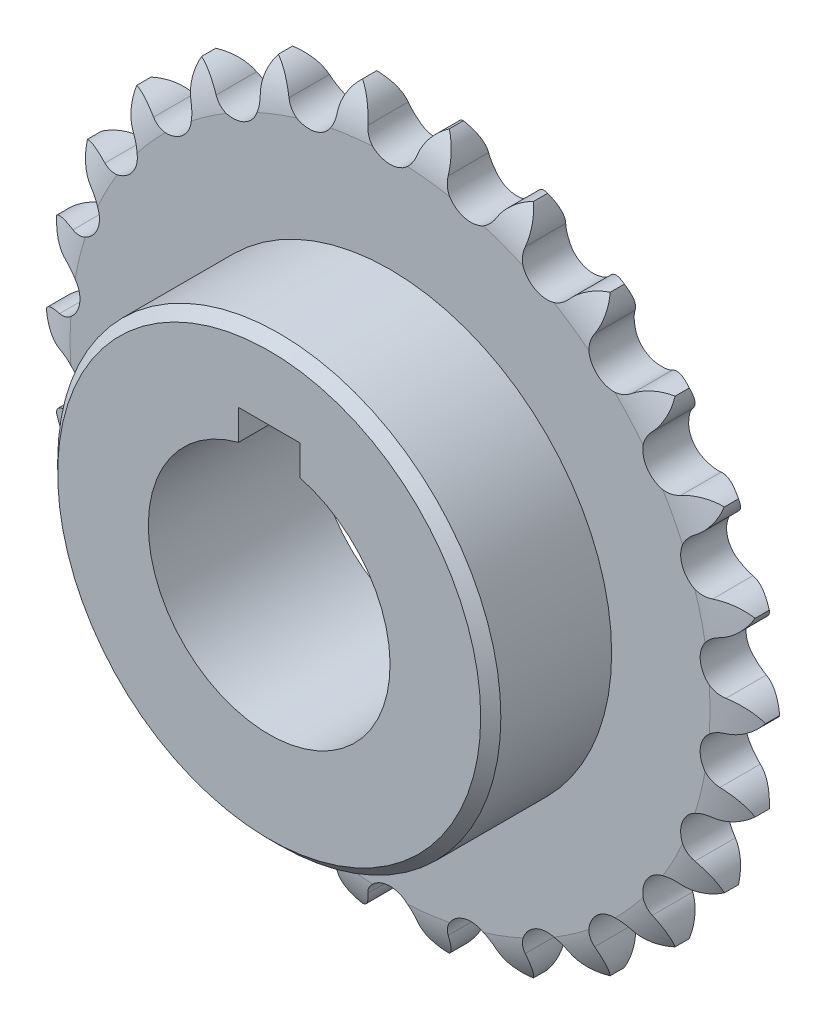
from build123d import *

# Parameters (mm, degrees)
SKETCH1_R           = 19.05
BOSS_EXTRUDE1_DEPTH = 3.6155
SKETCH2_W           = 19.05
SKETCH2_H           = 15.875
SKETCH3_W           = 9.65
SKETCH3_H           = 4.76
CUT_EXTRUDE1_DEPTH  = 27.281
CHAMFER2_SIZE       = 1.5875
SCALE_1_SCALE       = 0.5
SCALE_2_SCALE       = 2
SCALE_3_SCALE       = 0.111111111


with BuildPart() as part:
    # Sketch1 → Boss-Extrude1 (new body, symmetric)
    with BuildSketch(Plane.XY):
        with BuildLine():
            ThreePointArc((6.832203091, 56.268254805), (4.963717297, 54.655608899), (3.929721647, 52.414466562))
            ThreePointArc((3.929721647, 52.414466562), (0, 49.2633), (-3.929721647, 52.414466562))
            ThreePointArc((-3.929721647, 52.414466562), (-4.963717297, 54.655608899), (-6.832203091, 56.268254805))
            ThreePointArc((-6.832203091, 56.268254805), (-8.260462658, 54.25531154), (-8.728071806, 51.831841369))
            ThreePointArc((-8.728071806, 51.831841369), (-11.789479364, 47.831798034), (-16.359133961, 49.950953477))
            ThreePointArc((-16.359133961, 49.950953477), (-17.899424044, 51.879520935), (-20.099546463, 52.998148363))
            ThreePointArc((-20.099546463, 52.998148363), (-21.004574548, 50.701892683), (-20.87862145, 48.236937958))
            ThreePointArc((-20.87862145, 48.236937958), (-22.893797041, 43.620485829), (-27.837812873, 44.58447254))
            ThreePointArc((-27.837812873, 44.58447254), (-29.794881328, 46.088383789), (-32.198777254, 46.647982178))
            ThreePointArc((-32.198777254, 46.647982178), (-32.527976914, 44.201864118), (-31.815781507, 41.838679046))
            ThreePointArc((-31.815781507, 41.838679046), (-32.66761045, 36.87410954), (-37.698659287, 36.626904117))
            ThreePointArc((-37.698659287, 36.626904117), (-39.958768409, 37.618757301), (-42.426732148, 37.586804827))
            ThreePointArc((-42.426732148, 37.586804827), (-42.160971496, 35.132983877), (-40.903923988, 33.008908185))
            ThreePointArc((-40.903923988, 33.008908185), (-40.542901081, 27.984744038), (-45.368596652, 26.54071316))
            ThreePointArc((-45.368596652, 26.54071316), (-47.800397114, 26.962865377), (-50.188999585, 26.341219003))
            ThreePointArc((-50.188999585, 26.341219003), (-49.343723664, 24.022302317), (-47.614879086, 22.260779564))
            ThreePointArc((-47.614879086, 22.260779564), (-46.061985668, 17.469006932), (-50.401876088, 14.912072425))
            ThreePointArc((-50.401876088, 14.912072425), (-52.864040486, 14.739989724), (-55.034464796, 13.564777276))
            ThreePointArc((-55.034464796, 13.564777276), (-53.658797969, 11.515531863), (-51.558630485, 10.218935348))
            ThreePointArc((-51.558630485, 10.218935348), (-48.904115077, 5.93803464), (-52.505981689, 2.416796245))
            ThreePointArc((-52.505981689, 2.416796245), (-54.855417978, 1.660479445), (-56.681526955, 0))
            ThreePointArc((-56.681526955, 0), (-54.855417978, -1.660479445), (-52.505981689, -2.416796245))
            ThreePointArc((-52.505981689, -2.416796245), (-48.904115077, -5.93803464), (-51.558630485, -10.218935348))
            ThreePointArc((-51.558630485, -10.218935348), (-53.658797969, -11.515531863), (-55.034464796, -13.564777276))
            ThreePointArc((-55.034464796, -13.564777276), (-52.864040486, -14.739989724), (-50.401876088, -14.912072425))
            ThreePointArc((-50.401876088, -14.912072425), (-46.061985668, -17.469006932), (-47.614879086, -22.260779564))
            ThreePointArc((-47.614879086, -22.260779564), (-49.343723664, -24.022302317), (-50.188999585, -26.341219003))
            ThreePointArc((-50.188999585, -26.341219003), (-47.800397114, -26.962865377), (-45.368596652, -26.54071316))
            ThreePointArc((-45.368596652, -26.54071316), (-40.542901081, -27.984744038), (-40.903923988, -33.008908185))
            ThreePointArc((-40.903923988, -33.008908185), (-42.160971496, -35.132983877), (-42.426732148, -37.586804827))
            ThreePointArc((-42.426732148, -37.586804827), (-39.958768409, -37.618757301), (-37.698659287, -36.626904117))
            ThreePointArc((-37.698659287, -36.626904117), (-32.66761045, -36.87410954), (-31.815781507, -41.838679046))
            ThreePointArc((-31.815781507, -41.838679046), (-32.527976914, -44.201864118), (-32.198777254, -46.647982178))
            ThreePointArc((-32.198777254, -46.647982178), (-29.794881328, -46.088383789), (-27.837812873, -44.58447254))
            ThreePointArc((-27.837812873, -44.58447254), (-22.893797041, -43.620485829), (-20.87862145, -48.236937958))
            ThreePointArc((-20.87862145, -48.236937958), (-21.004574548, -50.701892683), (-20.099546463, -52.998148363))
            ThreePointArc((-20.099546463, -52.998148363), (-17.899424044, -51.879520935), (-16.359133961, -49.950953477))
            ThreePointArc((-16.359133961, -49.950953477), (-11.789479364, -47.831798034), (-8.728071806, -51.831841369))
            ThreePointArc((-8.728071806, -51.831841369), (-8.260462658, -54.25531154), (-6.832203091, -56.268254805))
            ThreePointArc((-6.832203091, -56.268254805), (-4.963717297, -54.655608899), (-3.929721647, -52.414466562))
            ThreePointArc((-3.929721647, -52.414466562), (0, -49.2633), (3.929721647, -52.414466562))
            ThreePointArc((3.929721647, -52.414466562), (4.963717297, -54.655608899), (6.832203091, -56.268254805))
            ThreePointArc((6.832203091, -56.268254805), (8.260462658, -54.25531154), (8.728071806, -51.831841369))
            ThreePointArc((8.728071806, -51.831841369), (11.789479365, -47.831798034), (16.359133961, -49.950953477))
            ThreePointArc((16.359133961, -49.950953477), (17.899424044, -51.879520935), (20.099546463, -52.998148363))
            ThreePointArc((20.099546463, -52.998148363), (21.004574548, -50.701892683), (20.87862145, -48.236937958))
            ThreePointArc((20.87862145, -48.236937958), (22.893797041, -43.620485829), (27.837812873, -44.58447254))
            ThreePointArc((27.837812873, -44.58447254), (29.794881328, -46.088383789), (32.198777254, -46.647982178))
            ThreePointArc((32.198777254, -46.647982178), (32.527976914, -44.201864118), (31.815781507, -41.838679046))
            ThreePointArc((31.815781507, -41.838679046), (32.66761045, -36.87410954), (37.698659287, -36.626904117))
            ThreePointArc((37.698659287, -36.626904117), (39.958768409, -37.618757301), (42.426732148, -37.586804827))
            ThreePointArc((42.426732148, -37.586804827), (42.160971496, -35.132983877), (40.903923988, -33.008908185))
            ThreePointArc((40.903923988, -33.008908185), (40.542901081, -27.984744038), (45.368596652, -26.54071316))
            ThreePointArc((45.368596652, -26.54071316), (47.800397114, -26.962865377), (50.188999585, -26.341219003))
            ThreePointArc((50.188999585, -26.341219003), (49.343723664, -24.022302317), (47.614879086, -22.260779564))
            ThreePointArc((47.614879086, -22.260779564), (46.061985668, -17.469006932), (50.401876088, -14.912072425))
            ThreePointArc((50.401876088, -14.912072425), (52.864040486, -14.739989724), (55.034464796, -13.564777276))
            ThreePointArc((55.034464796, -13.564777276), (53.658797969, -11.515531863), (51.558630485, -10.218935348))
            ThreePointArc((51.558630485, -10.218935348), (48.904115077, -5.93803464), (52.505981689, -2.416796245))
            ThreePointArc((52.505981689, -2.416796245), (54.855417978, -1.660479445), (56.681526955, 0))
            ThreePointArc((56.681526955, 0), (54.855417978, 1.660479445), (52.505981689, 2.416796245))
            ThreePointArc((52.505981689, 2.416796245), (48.904115077, 5.93803464), (51.558630485, 10.218935348))
            ThreePointArc((51.558630485, 10.218935348), (53.658797969, 11.515531863), (55.034464796, 13.564777276))
            ThreePointArc((55.034464796, 13.564777276), (52.864040486, 14.739989724), (50.401876088, 14.912072425))
            ThreePointArc((50.401876088, 14.912072425), (46.061985668, 17.469006932), (47.614879086, 22.260779564))
            ThreePointArc((47.614879086, 22.260779564), (49.343723664, 24.022302317), (50.188999585, 26.341219003))
            ThreePointArc((50.188999585, 26.341219003), (47.800397114, 26.962865377), (45.368596652, 26.54071316))
            ThreePointArc((45.368596652, 26.54071316), (40.542901081, 27.984744038), (40.903923988, 33.008908185))
            ThreePointArc((40.903923988, 33.008908185), (42.160971496, 35.132983877), (42.426732148, 37.586804827))
            ThreePointArc((42.426732148, 37.586804827), (39.958768409, 37.618757301), (37.698659287, 36.626904117))
            ThreePointArc((37.698659287, 36.626904117), (32.66761045, 36.87410954), (31.815781507, 41.838679046))
            ThreePointArc((31.815781507, 41.838679046), (32.527976914, 44.201864118), (32.198777254, 46.647982178))
            ThreePointArc((32.198777254, 46.647982178), (29.794881328, 46.088383789), (27.837812873, 44.58447254))
            ThreePointArc((27.837812873, 44.58447254), (22.893797041, 43.620485829), (20.87862145, 48.236937958))
            ThreePointArc((20.87862145, 48.236937958), (21.004574548, 50.701892683), (20.099546463, 52.998148363))
            ThreePointArc((20.099546463, 52.998148363), (17.899424044, 51.879520935), (16.359133961, 49.950953477))
            ThreePointArc((16.359133961, 49.950953477), (11.789479364, 47.831798034), (8.728071806, 51.831841369))
            ThreePointArc((8.728071806, 51.831841369), (8.260462658, 54.25531154), (6.832203091, 56.268254805))
        make_face()
        Circle(SKETCH1_R, mode=Mode.SUBTRACT)
    extrude(amount=BOSS_EXTRUDE1_DEPTH, both=True)

    # Sketch2 → Revolve1 (revolve)
    with BuildSketch(Plane(origin=(0, 0, 0), x_dir=(0, 0, -1), z_dir=(1, 0, 0))):
        with Locations((-13.1405, 26.9875)):
            Rectangle(SKETCH2_W, SKETCH2_H)
    revolve(axis=Axis((0, 0, 0), (0, 0, 1)))

    # Sketch3 → Cut-Extrude1 (cut, through all)
    with BuildSketch(Plane.XY.offset(22.6655)):
        with Locations((0, 20.808832709)):
            Rectangle(SKETCH3_W, SKETCH3_H)
    extrude(amount=-CUT_EXTRUDE1_DEPTH, mode=Mode.SUBTRACT)

    # Sketch4 → Cut-Revolve1 (revolve, cut)
    with BuildSketch(Plane(origin=(0, 0, 0), x_dir=(0, 0, -1), z_dir=(1, 0, 0))):
        with BuildLine():
            Line((-3.6155, 50.42), (-12.330867659, 50.42))
            Line((-12.330867659, 50.42), (-12.330867659, 56.89))
            Line((-12.330867659, 56.89), (-0.954045736, 56.89))
            ThreePointArc((-0.954045736, 56.89), (-2.739073023, 53.841877757), (-3.6155, 50.42))
        make_face()
    cut_revolve1 = revolve(axis=Axis((0, 0, 0), (0, 0, 1)), mode=Mode.SUBTRACT)

    # Mirror1: Cut-Revolve1 across plane
    add(cut_revolve1.mirror(Plane.XY), mode=Mode.SUBTRACT)

    # Chamfer2
    chamfer2_edges = [part.edges().sort_by_distance(p)[0] for p in [
        (0, -34.925, 22.6655),
    ]]
    chamfer(chamfer2_edges, length=CHAMFER2_SIZE)


with BuildPart() as part_1:
    # Scale 1: scaled about (-9e-09, -0.225936899, 6.41471309)
    add(part.part.scale(SCALE_1_SCALE).moved(Location((-4e-09, -0.112968449, 3.207356545))))


with BuildPart() as part_2:
    # Scale 2: scaled about (-9e-09, -0.225936899, 6.41471309)
    add(part_1.part.scale(SCALE_2_SCALE).moved(Location((9e-09, 0.225936899, -6.41471309))))


with BuildPart() as part_3:
    # Scale 3: scaled about (-9e-09, -0.225936899, 6.41471309)
    add(part_2.part.scale(SCALE_3_SCALE).moved(Location((-8e-09, -0.200832799, 5.701967191))))


solid = part_3.part
